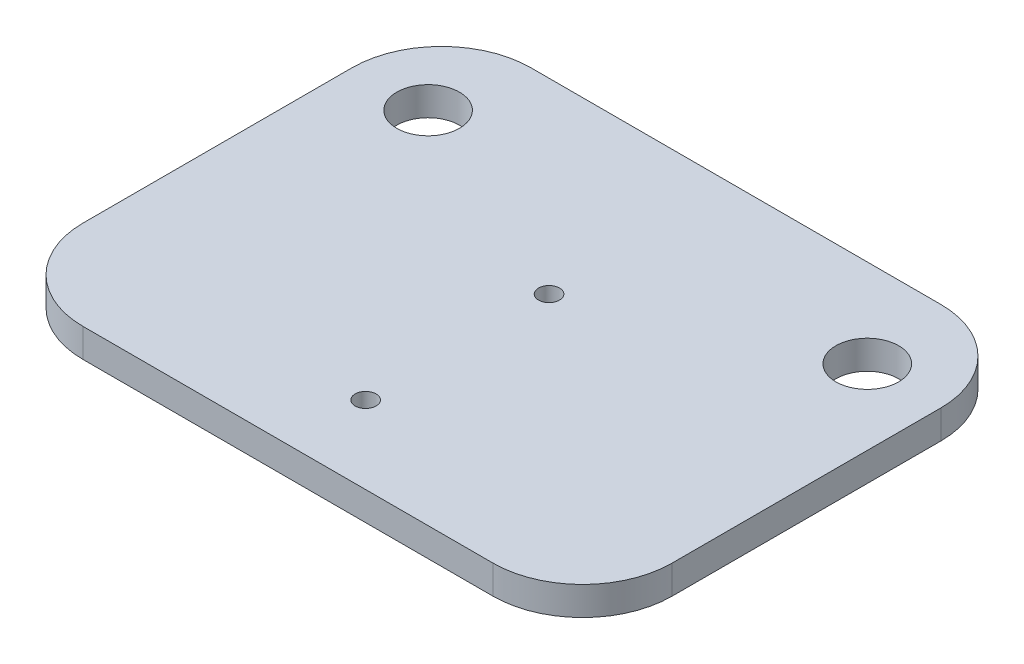
from build123d import *

# Parameters (mm, degrees)
BOSS_EXTRUDE1_DEPTH = 0.8128
SKETCH2_R           = 0.889
SKETCH2_R_2         = 0.297244981
CUT_EXTRUDE1_DEPTH  = 8.4328


with BuildPart() as part:
    # Sketch1 → Boss-Extrude1 (new body)
    with BuildSketch(Plane(origin=(0, 0, 0), x_dir=(1, 0, 0), z_dir=(0, 1, 0))):
        with BuildLine():
            Line((-5.81, -6.35), (5.81, -6.35))
            ThreePointArc((5.81, -6.35), (7.606051224, -5.606051224), (8.35, -3.81))
            Line((8.35, -3.81), (8.35, 3.81))
            ThreePointArc((8.35, 3.81), (7.606051224, 5.606051224), (5.81, 6.35))
            Line((5.81, 6.35), (-5.81, 6.35))
            ThreePointArc((-5.81, 6.35), (-7.606051224, 5.606051224), (-8.35, 3.81))
            Line((-8.35, 3.81), (-8.35, -3.81))
            ThreePointArc((-8.35, -3.81), (-7.606051224, -5.606051224), (-5.81, -6.35))
        make_face()
    extrude(amount=BOSS_EXTRUDE1_DEPTH)

    # Sketch2 → Cut-Extrude1 (cut)
    with BuildSketch(Plane(origin=(0, 2.54, 0), x_dir=(1, 0, 0), z_dir=(0, 1, 0))):
        with Locations((-6.2283636, 3.85)):
            Circle(SKETCH2_R)
        with Locations((6.223, 3.85)):
            Circle(SKETCH2_R)
        with Locations((0, -4.15)):
            Circle(SKETCH2_R_2)
        with Locations((0, 1.05)):
            Circle(SKETCH2_R_2)
    extrude(amount=-CUT_EXTRUDE1_DEPTH, mode=Mode.SUBTRACT)


solid = part.part
